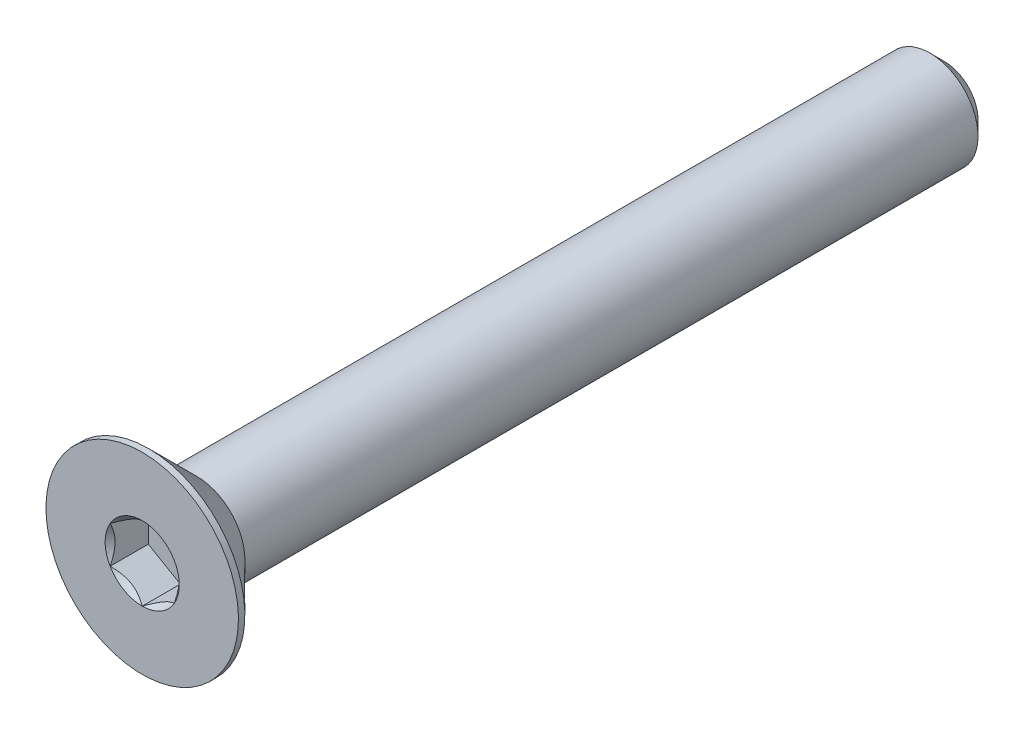
from build123d import *

# Parameters (mm, degrees)
SKETCH3_W          = 25
SKETCH3_H          = 1.5
CHAMFER1_SIZE      = 0.45
CUT_EXTRUDE1_DEPTH = 1.19


with BuildPart() as part:
    # Sketch3 → Revolve1 (revolve)
    with BuildSketch(Plane(origin=(0, 0, 0), x_dir=(0, 0, -1), z_dir=(1, 0, 0))):
        with Locations((0, 0.75)):
            Rectangle(SKETCH3_W, SKETCH3_H)
    revolve(axis=Axis((0, 0, -12.5), (0, 0, 1)))

    # Chamfer1
    chamfer1_edges = [part.edges().sort_by_distance(p)[0] for p in [
        (0, -1.5, -12.5),
    ]]
    chamfer(chamfer1_edges, length=CHAMFER1_SIZE)

    # Sketch6 → Revolve2 (revolve)
    with BuildSketch(Plane(origin=(0, 0, 0), x_dir=(0, 0, -1), z_dir=(1, 0, 0))):
        Polygon((-12.5, 3), (-12.3, 3), (-10.8, 1.5), (-10.8, 0), (-12.5, 0), align=None)
    revolve(axis=Axis((0, 0, -12.5), (0, 0, 1)))

    # Sketch8 → Cut-Extrude1 (cut)
    with BuildSketch(Plane.XY.offset(12.5)):
        Polygon((0, 1.154700538), (-1, 0.577350269), (-1, -0.577350269), (0, -1.154700538), (1, -0.577350269), (1, 0.577350269), align=None)
    extrude(amount=-CUT_EXTRUDE1_DEPTH, mode=Mode.SUBTRACT)

    # Cut-Extrude2 cone 1 section (through the dimple's axis) → Cut-Extrude2 (revolve, cut)
    with BuildSketch(Plane(origin=(0, 0, 12.5), x_dir=(0, -1, 0), z_dir=(1, 0, 0))):
        Polygon((0, 0), (1.154700538, 0), (0, 1.154700538), align=None)
    revolve(axis=Axis((0, 0, 12.5), (0, 0, -1)), mode=Mode.SUBTRACT)


solid = part.part
